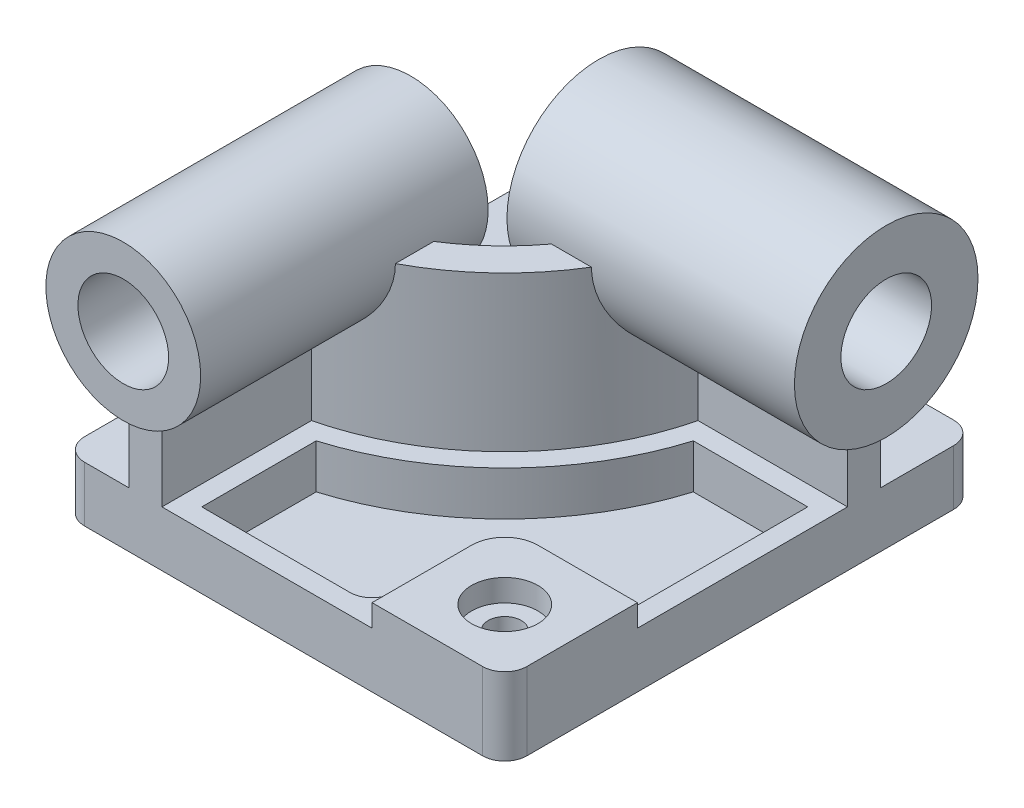
from build123d import *

# Parameters (mm, degrees)
SKETCH1_W                = 200
SKETCH1_H                = 213
BOSS_EXTRUDE1_DEPTH      = 12.5
FILLET1_R                = 10
BOSS_EXTRUDE2_DEPTH      = 70
BOSS_EXTRUDE3_DEPTH      = 10
CUT_EXTRUDE1_DEPTH       = 20
SKETCH5_R                = 7.5
CUT_EXTRUDE2_DEPTH       = 20
SKETCH6_R                = 15
CUT_EXTRUDE3_DEPTH       = 10
SKETCH8_R                = 35
BOSS_EXTRUDE4_DEPTH      = 10
BOSS_EXTRUDE4_DEPTH_BACK = 120
SKETCH9_R                = 20.5
CUT_EXTRUDE4_DEPTH       = 224
SKETCH10_R               = 41.5
SKETCH10_R_2             = 20.5
BOSS_EXTRUDE5_DEPTH      = 10
BOSS_EXTRUDE5_DEPTH_BACK = 120
SKETCH11_R               = 20.5
CUT_EXTRUDE5_DEPTH       = 201


with BuildPart() as part:
    # Sketch1 → Boss-Extrude1 (new body, symmetric)
    with BuildSketch(Plane(origin=(0, 0, 0), x_dir=(1, 0, 0), z_dir=(0, 1, 0))):
        Rectangle(SKETCH1_W, SKETCH1_H)
    extrude(amount=BOSS_EXTRUDE1_DEPTH, both=True)

    # Fillet1
    fillet1_edges = [part.edges().sort_by_distance(p)[0] for p in [
        (100, 0, 106.5),
        (-100, 0, 106.5),
        (-100, 0, -106.5),
        (100, 0, -106.5),
    ]]
    fillet(fillet1_edges, radius=FILLET1_R)

    # Sketch2 → Boss-Extrude2 (add)
    with BuildSketch(Plane(origin=(0, 12.5, 0), x_dir=(1, 0, 0), z_dir=(0, 1, 0))):
        with BuildLine():
            Line((-70, -106.5), (-55, -106.5))
            Line((-55, -106.5), (-55, -38.928392203))
            ThreePointArc((-55, -38.928392203), (0.920301962, -7.420301962), (32.428392203, 48.5))
            Line((32.428392203, 48.5), (100, 48.5))
            Line((100, 48.5), (100, 63.5))
            Line((100, 63.5), (20, 63.5))
            ThreePointArc((20, 63.5), (-9.686299755, 3.186299755), (-70, -26.5))
            Line((-70, -26.5), (-70, -106.5))
        make_face()
    extrude(amount=BOSS_EXTRUDE2_DEPTH)

    # Sketch3 → Boss-Extrude3 (add)
    with BuildSketch(Plane(origin=(0, 12.5, 0), x_dir=(1, 0, 0), z_dir=(0, 1, 0))):
        with BuildLine():
            Line((100, -46.5), (55, -46.5))
            ThreePointArc((55, -46.5), (44.393398282, -50.893398282), (40, -61.5))
            Line((40, -61.5), (40, -106.5))
            Line((40, -106.5), (90, -106.5))
            ThreePointArc((90, -106.5), (97.071067812, -103.571067812), (100, -96.5))
            Line((100, -96.5), (100, -46.5))
        make_face()
    extrude(amount=BOSS_EXTRUDE3_DEPTH)

    # Sketch4 → Cut-Extrude1 (cut)
    with BuildSketch(Plane(origin=(0, 12.5, 0), x_dir=(1, 0, 0), z_dir=(0, 1, 0))):
        with BuildLine():
            Line((-46, -97.5), (-46, -45.782855831))
            ThreePointArc((-46, -45.782855831), (7.284262993, -13.784262993), (39.282855831, 39.5))
            Line((39.282855831, 39.5), (91, 39.5))
            Line((91, 39.5), (91, -37.5))
            Line((91, -37.5), (55, -37.5))
            ThreePointArc((55, -37.5), (38.029437252, -44.529437252), (31, -61.5))
            Line((31, -61.5), (31, -87.5))
            ThreePointArc((31, -87.5), (28.071067812, -94.571067812), (21, -97.5))
            Line((21, -97.5), (-46, -97.5))
        make_face()
    extrude(amount=-CUT_EXTRUDE1_DEPTH, mode=Mode.SUBTRACT)

    # Sketch5 → Cut-Extrude2 (cut)
    with BuildSketch(Plane(origin=(0, 22.5, 0), x_dir=(1, 0, 0), z_dir=(0, 1, 0))):
        with Locations((70.732233047, -77.232233047)):
            Circle(SKETCH5_R)
    extrude(amount=-CUT_EXTRUDE2_DEPTH, mode=Mode.SUBTRACT)

    # Sketch6 → Cut-Extrude3 (cut)
    with BuildSketch(Plane(origin=(0, 22.5, 0), x_dir=(1, 0, 0), z_dir=(0, 1, 0))):
        with Locations((70.732233047, -77.232233047)):
            Circle(SKETCH6_R)
    extrude(amount=-CUT_EXTRUDE3_DEPTH, mode=Mode.SUBTRACT)

    # Sketch8 → Boss-Extrude4 (add, two sides)
    with BuildSketch(Plane.XY.offset(106.5)) as boss_extrude4_sk:
        with Locations((-62.5, 82.5)):
            Circle(SKETCH8_R)
    extrude(amount=BOSS_EXTRUDE4_DEPTH)
    extrude(boss_extrude4_sk.sketch, amount=-BOSS_EXTRUDE4_DEPTH_BACK)

    # Sketch9 → Cut-Extrude4 (cut, through all)
    with BuildSketch(Plane.XY.offset(116.5)):
        with Locations((-62.5, 82.5)):
            Circle(SKETCH9_R)
    extrude(amount=-CUT_EXTRUDE4_DEPTH, mode=Mode.SUBTRACT)

    # Sketch10 → Boss-Extrude5 (add, two sides)
    with BuildSketch(Plane(origin=(100, 0, 0), x_dir=(0, 0, -1), z_dir=(1, 0, 0))) as boss_extrude5_sk:
        with Locations((56, 82.5)):
            Circle(SKETCH10_R)
        with Locations((56, 82.5)):
            Circle(SKETCH10_R_2, mode=Mode.SUBTRACT)
    extrude(amount=BOSS_EXTRUDE5_DEPTH)
    extrude(boss_extrude5_sk.sketch, amount=-BOSS_EXTRUDE5_DEPTH_BACK)

    # Sketch11 → Cut-Extrude5 (cut, through all)
    with BuildSketch(Plane(origin=(100, 0, 0), x_dir=(0, 0, -1), z_dir=(1, 0, 0))):
        with Locations((56, 82.5)):
            Circle(SKETCH11_R)
    extrude(amount=-CUT_EXTRUDE5_DEPTH, mode=Mode.SUBTRACT)


solid = part.part
